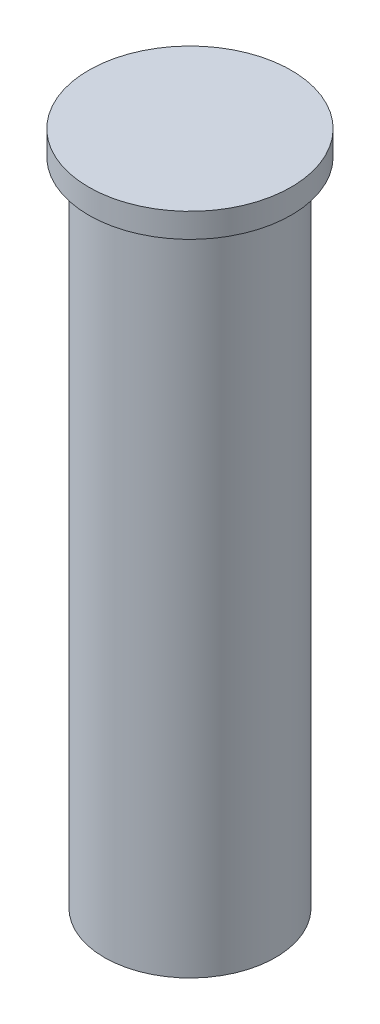
from build123d import *

# Parameters (mm, degrees)
SKETCH1_R                       = 4.7625
BOSS_EXTRUDE1_DEPTH             = 1.143
BOSS_EXTRUDE2_START             = -1.143
SKETCH2_R                       = 4.0259
BOSS_EXTRUDE2_DEPTH             = 31.75
F_8_32_TAPPED_HOLE1_D           = 3.4544
F_8_32_TAPPED_HOLE1_DEPTH       = 19.05
F_8_32_TAPPED_HOLE1_CSINK_D     = 5.4356
F_8_32_TAPPED_HOLE1_CSINK_ANGLE = 45
F_8_32_TAPPED_HOLE1_TIP         = 1.037806461


with BuildPart() as part:
    # Sketch1 → Boss-Extrude1 (new body)
    with BuildSketch(Plane(origin=(0, 0, 0), x_dir=(1, 0, 0), z_dir=(0, 1, 0))):
        Circle(SKETCH1_R)
    extrude(amount=BOSS_EXTRUDE1_DEPTH)

    # Sketch2 → Boss-Extrude2 (add)
    with BuildSketch(Plane.XZ.offset(BOSS_EXTRUDE2_START)):
        Circle(SKETCH2_R)
    extrude(amount=BOSS_EXTRUDE2_DEPTH)

    # #8-32 Tapped Hole1
    with Locations(Plane(origin=(0, -30.607, 0), x_dir=(-1, 0, 0), z_dir=(0, -1, 0))):
        with Locations((0, 0)):
            CounterSinkHole(F_8_32_TAPPED_HOLE1_D / 2, F_8_32_TAPPED_HOLE1_CSINK_D / 2, depth=F_8_32_TAPPED_HOLE1_DEPTH, counter_sink_angle=F_8_32_TAPPED_HOLE1_CSINK_ANGLE)
            with Locations((0, 0, -(F_8_32_TAPPED_HOLE1_DEPTH + F_8_32_TAPPED_HOLE1_TIP / 2))):  # 118° drill point
                Cone(0, F_8_32_TAPPED_HOLE1_D / 2, F_8_32_TAPPED_HOLE1_TIP, mode=Mode.SUBTRACT)


solid = part.part
